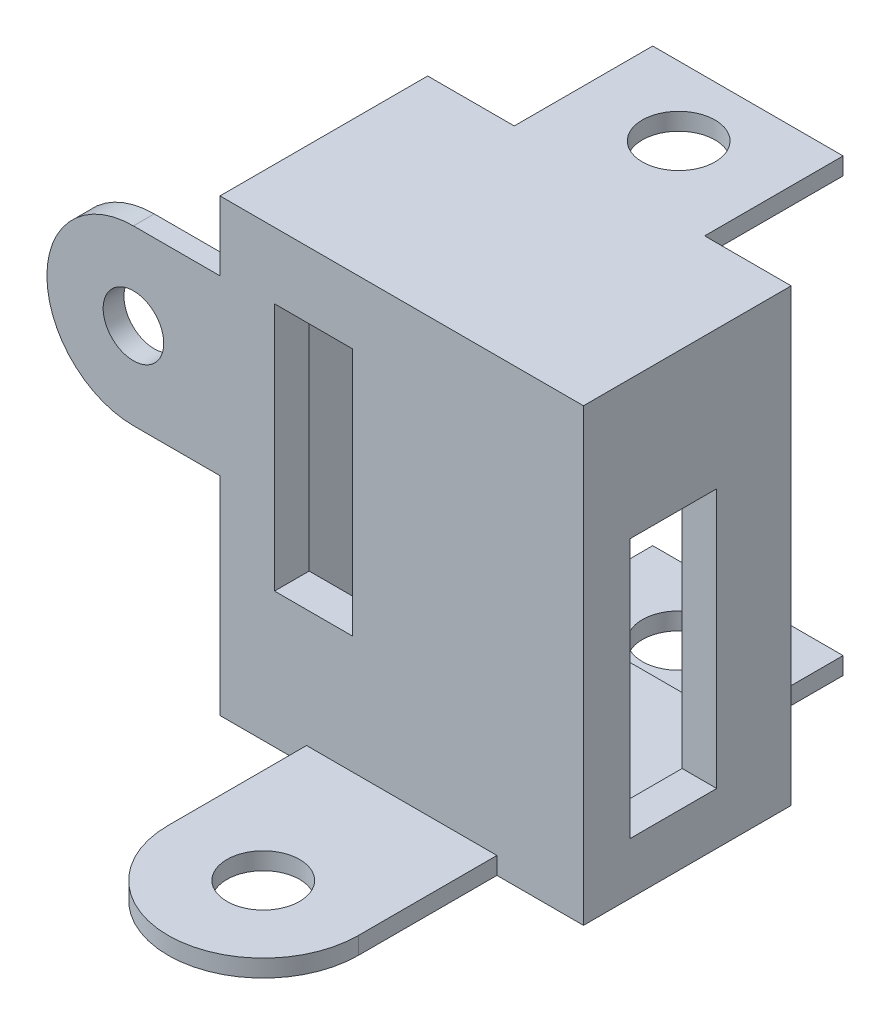
from build123d import *

# Parameters (mm, degrees)
SKETCH1_W            = 21
SKETCH1_H            = 26
SKETCH1_W_2          = 17
SKETCH1_H_2          = 21
BOSS_EXTRUDE1_DEPTH  = 10
SKETCH2_W            = 21
SKETCH2_H            = 26
BOSS_EXTRUDE2_DEPTH  = 2
SKETCH4_W            = 5
SKETCH4_H            = 15
CUT_EXTRUDE2_DEPTH   = 2
SKETCH6_R            = 1.76
BOSS_EXTRUDE3_DEPTH  = 2
SKETCH9_R            = 1.76
BOSS_EXTRUDE5_DEPTH  = 2
SKETCH14_W           = 11
SKETCH14_H           = 1
BOSS_EXTRUDE8_DEPTH  = 8
SKETCH16_R           = 2.1
CUT_EXTRUDE3_DEPTH   = 36
SKETCH17_R           = 1.75
BOSS_EXTRUDE9_DEPTH  = 1.2
SKETCH18_W           = 11
SKETCH18_H           = 14.770488881
CUT_EXTRUDE4_DEPTH   = 3.2
SKETCH19_W           = 11
SKETCH19_H           = 14.236904858
CUT_EXTRUDE5_DEPTH   = 10
SKETCH20_R           = 2.1
BOSS_EXTRUDE10_DEPTH = 1
SKETCH22_W           = 4.498408698
SKETCH22_H           = 14.372964376
CUT_EXTRUDE6_DEPTH   = 10


with BuildPart() as part:
    # Sketch1 → Boss-Extrude1 (new body)
    with BuildSketch(Plane.XY):
        Rectangle(SKETCH1_W, SKETCH1_H)
        Rectangle(SKETCH1_W_2, SKETCH1_H_2, mode=Mode.SUBTRACT)
    extrude(amount=BOSS_EXTRUDE1_DEPTH)

    # Sketch2 → Boss-Extrude2 (add)
    with BuildSketch(Plane.XY.offset(10)):
        Rectangle(SKETCH2_W, SKETCH2_H)
    extrude(amount=BOSS_EXTRUDE2_DEPTH)

    # Sketch4 → Cut-Extrude2 (cut)
    with BuildSketch(Plane(origin=(10.5, 0, 0), x_dir=(0, 0, -1), z_dir=(1, 0, 0))):
        with Locations((-6.8, -2.5)):
            Rectangle(SKETCH4_W, SKETCH4_H)
    extrude(amount=-CUT_EXTRUDE2_DEPTH, mode=Mode.SUBTRACT)

    # Sketch6 → Boss-Extrude3 (add)
    with BuildSketch(Plane.XY.offset(12)):
        with BuildLine():
            Line((0, 13), (5.5, 13))
            Line((5.5, 13), (5.5, 18))
            ThreePointArc((5.5, 18), (0, 23.5), (-5.5, 18))
            Line((-5.5, 18), (-5.5, 13))
            Line((-5.5, 13), (0, 13))
        make_face()
        with Locations((0, 18)):
            Circle(SKETCH6_R, mode=Mode.SUBTRACT)
    extrude(amount=-BOSS_EXTRUDE3_DEPTH)

    # Sketch9 → Boss-Extrude5 (add)
    with BuildSketch(Plane.XY.offset(12)):
        with BuildLine():
            Line((0, -13), (-5.5, -13))
            Line((-5.5, -13), (-5.5, -18))
            ThreePointArc((-5.5, -18), (0, -23.5), (5.5, -18))
            Line((5.5, -18), (5.5, -13))
            Line((5.5, -13), (0, -13))
        make_face()
        with Locations((0, -18)):
            Circle(SKETCH9_R, mode=Mode.SUBTRACT)
    extrude(amount=-BOSS_EXTRUDE5_DEPTH)

    # Sketch14 → Boss-Extrude8 (add)
    with BuildSketch(Plane(origin=(0, 0, 0), x_dir=(-1, 0, 0), z_dir=(0, 0, -1))):
        with Locations((0, -12.5)):
            Rectangle(SKETCH14_W, SKETCH14_H)
        with Locations((0, 12.5)):
            Rectangle(SKETCH14_W, SKETCH14_H)
    extrude(amount=BOSS_EXTRUDE8_DEPTH)

    # Sketch16 → Cut-Extrude3 (cut)
    with BuildSketch(Plane(origin=(0, 13, 0), x_dir=(1, 0, 0), z_dir=(0, 1, 0))):
        with Locations((0, 4)):
            Circle(SKETCH16_R)
    extrude(amount=-CUT_EXTRUDE3_DEPTH, mode=Mode.SUBTRACT)

    # Sketch17 → Boss-Extrude9 (add)
    with BuildSketch(Plane.XY.offset(12)):
        with BuildLine():
            Line((-15.5, -1), (-10.5, -1))
            Line((-10.5, -1), (-10.5, 9))
            Line((-10.5, 9), (-15.5, 9))
            ThreePointArc((-15.5, 9), (-20.5, 4), (-15.5, -1))
        make_face()
        with Locations((-15.5, 4)):
            Circle(SKETCH17_R, mode=Mode.SUBTRACT)
    extrude(amount=-BOSS_EXTRUDE9_DEPTH)

    # Sketch18 → Cut-Extrude4 (cut)
    with BuildSketch(Plane.XY.offset(12)):
        with Locations((0, 20.385244441)):
            Rectangle(SKETCH18_W, SKETCH18_H)
    extrude(amount=-CUT_EXTRUDE4_DEPTH, mode=Mode.SUBTRACT)

    # Sketch19 → Cut-Extrude5 (cut)
    with BuildSketch(Plane.XY.offset(12)):
        with Locations((0, -20.118452429)):
            Rectangle(SKETCH19_W, SKETCH19_H)
    extrude(amount=-CUT_EXTRUDE5_DEPTH, mode=Mode.SUBTRACT)

    # Sketch20 → Boss-Extrude10 (add)
    with BuildSketch(Plane.XZ.offset(13)):
        with BuildLine():
            Line((0, 12), (5.5, 12))
            Line((5.5, 12), (5.5, 20))
            ThreePointArc((5.5, 20), (0, 25.5), (-5.5, 20))
            Line((-5.5, 20), (-5.5, 12))
            Line((-5.5, 12), (0, 12))
        make_face()
        with Locations((0, 20)):
            Circle(SKETCH20_R, mode=Mode.SUBTRACT)
    extrude(amount=-BOSS_EXTRUDE10_DEPTH)

    # Sketch22 → Cut-Extrude6 (cut)
    with BuildSketch(Plane(origin=(0, 0, 10), x_dir=(-1, 0, 0), z_dir=(0, 0, -1))):
        with Locations((5.100019104, 1.989760377)):
            Rectangle(SKETCH22_W, SKETCH22_H)
    extrude(amount=-CUT_EXTRUDE6_DEPTH, mode=Mode.SUBTRACT)


solid = part.part
